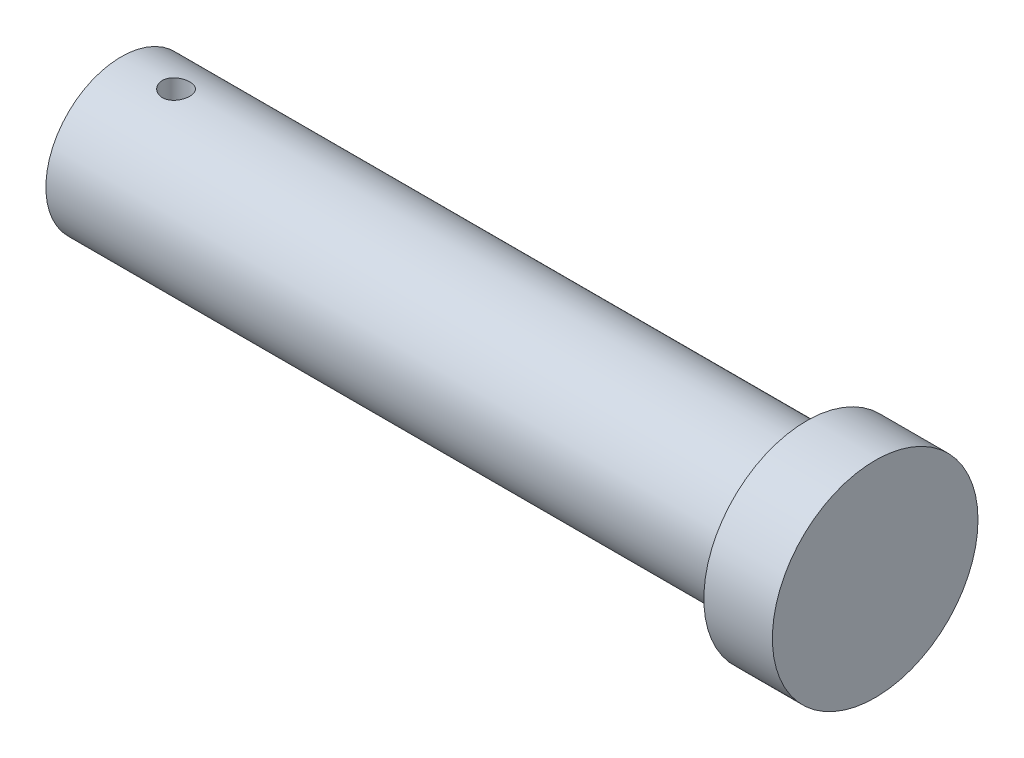
from build123d import *

# Parameters (mm, degrees)
SKETCH1_R               = 5.5
BOSS_EXTRUDE1_DEPTH     = 50
SKETCH2_R               = 7.5
BOSS_EXTRUDE2_DEPTH     = 5
SKETCH3_R               = 1
CUT_EXTRUDE1_DEPTH      = 8.5
CUT_EXTRUDE1_DEPTH_BACK = 8.5


with BuildPart() as part:
    # Sketch1 → Boss-Extrude1 (new body)
    with BuildSketch(Plane(origin=(0, 0, 0), x_dir=(0, 0, -1), z_dir=(1, 0, 0))):
        Circle(SKETCH1_R)
    extrude(amount=BOSS_EXTRUDE1_DEPTH)

    # Sketch2 → Boss-Extrude2 (add)
    with BuildSketch(Plane(origin=(50, 0, 0), x_dir=(0, 0, -1), z_dir=(1, 0, 0))):
        Circle(SKETCH2_R)
    extrude(amount=BOSS_EXTRUDE2_DEPTH)

    # Sketch3 → Cut-Extrude1 (cut, two sides)
    with BuildSketch(Plane(origin=(0, 0, 0), x_dir=(1, 0, 0), z_dir=(0, 1, 0))) as cut_extrude1_sk:
        with Locations((4, 0)):
            Circle(SKETCH3_R)
    extrude(amount=CUT_EXTRUDE1_DEPTH, mode=Mode.SUBTRACT)
    extrude(cut_extrude1_sk.sketch, amount=-CUT_EXTRUDE1_DEPTH_BACK, mode=Mode.SUBTRACT)


solid = part.part
